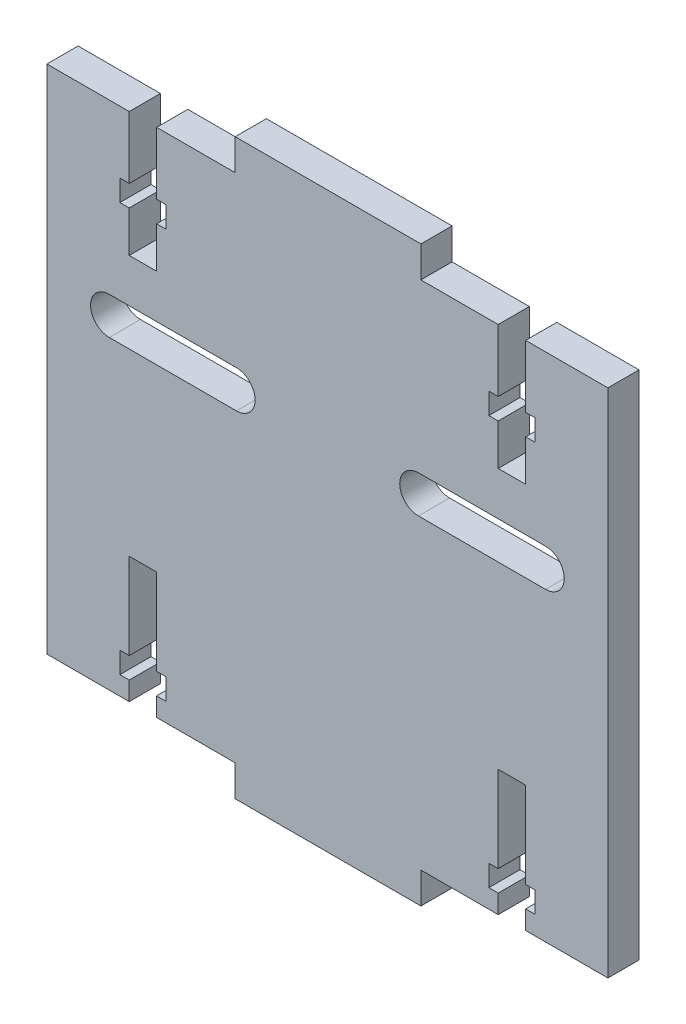
from build123d import *

# Parameters (mm, degrees)
SKETCH1_W           = 90
SKETCH1_H           = 82
BOSS_EXTRUDE1_DEPTH = 5
SKETCH4_W           = 29.8
SKETCH4_H           = 5
BOSS_EXTRUDE2_DEPTH = 5
CUT_EXTRUDE1_DEPTH  = 10
CUT_EXTRUDE2_DEPTH  = 10


with BuildPart() as part:
    # Sketch1 → Boss-Extrude1 (new body)
    with BuildSketch(Plane.XY):
        Rectangle(SKETCH1_W, SKETCH1_H)
    extrude(amount=BOSS_EXTRUDE1_DEPTH)

    # Sketch4 → Boss-Extrude2 (add)
    with BuildSketch(Plane.XY.offset(5)):
        with Locations((0.1, 43.5)):
            Rectangle(SKETCH4_W, SKETCH4_H)
    boss_extrude2 = extrude(amount=-BOSS_EXTRUDE2_DEPTH)

    # Mirror1: Boss-Extrude2 across plane
    add(boss_extrude2.mirror(Plane(origin=(0, 0, 0), x_dir=(0, 0, 1), z_dir=(0, -1, 0))))

    # Sketch5 → Cut-Extrude1 (cut)
    with BuildSketch(Plane.XY.offset(5)):
        Polygon((27.39999999, 41), (27.39999999, 31), (25.89999999, 31), (25.89999999, 27.6), (27.39999999, 27.6), (27.39999999, 21), (31.79999999, 21), (31.79999999, 27.6), (33.29999999, 27.6), (33.29999999, 31), (31.79999999, 31), (31.79999999, 41), align=None)
        Polygon((-27.39999999, 27.6), (-27.39999999, 21), (-31.79999999, 21), (-31.79999999, 27.6), (-33.29999999, 27.6), (-33.29999999, 31), (-31.79999999, 31), (-31.79999999, 41), (-27.39999999, 41), (-27.39999999, 31), (-25.89999999, 31), (-25.89999999, 27.6), align=None)
        Polygon((-27.4, -38), (-27.4, -41), (-31.8, -41), (-31.8, -38), (-33.3, -38), (-33.3, -34.6), (-31.8, -34.6), (-31.8, -20.8), (-27.4, -20.8), (-27.4, -34.6), (-25.9, -34.6), (-25.9, -38), align=None)
        Polygon((31.8, -41), (31.8, -38), (33.3, -38), (33.3, -34.6), (31.8, -34.6), (31.8, -20.8), (27.4, -20.8), (27.4, -34.6), (25.9, -34.6), (25.9, -38), (27.4, -38), (27.4, -41), align=None)
    extrude(amount=-CUT_EXTRUDE1_DEPTH, mode=Mode.SUBTRACT)

    # Sketch6 → Cut-Extrude2 (cut)
    with BuildSketch(Plane.XY.offset(5)):
        with BuildLine():
            Line((-14.6, 14), (-35, 14))
            ThreePointArc((-35, 14), (-38, 11), (-35, 8))
            Line((-35, 8), (-14.6, 8))
            ThreePointArc((-14.6, 8), (-11.6, 11), (-14.6, 14))
        make_face()
        with BuildLine():
            Line((35, 8), (14.6, 8))
            ThreePointArc((14.6, 8), (11.6, 11), (14.6, 14))
            Line((14.6, 14), (35, 14))
            ThreePointArc((35, 14), (38, 11), (35, 8))
        make_face()
    extrude(amount=-CUT_EXTRUDE2_DEPTH, mode=Mode.SUBTRACT)


solid = part.part
